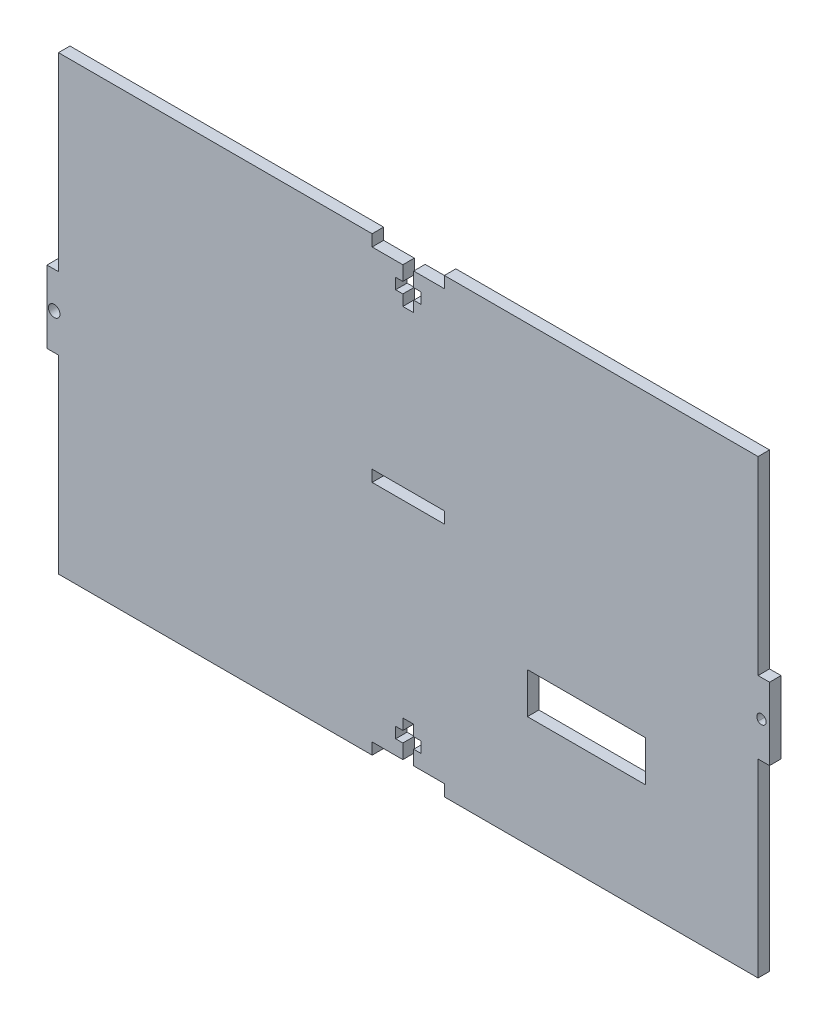
from build123d import *

# Parameters (mm, degrees)
SKETCH1_W               = 200
SKETCH1_H               = 125
BOSS_EXTRUDE1_DEPTH     = 3.18
SKETCH2_R               = 1.5
SKETCH2_W               = 3.18
SKETCH2_H               = 52.625
CUT_EXTRUDE1_DEPTH      = 4.18
SKETCH6_W               = 20
SKETCH6_H               = 3.18
CUT_EXTRUDE4_DEPTH      = 3.18
SKETCH7_W               = 32.709050062
SKETCH7_H               = 11.279604012
CUT_EXTRUDE5_DEPTH      = 3.18
SKETCH8_W               = 3.18
SKETCH8_H               = 19.75
CUT_EXTRUDE6_DEPTH      = 4.18
SKETCH9_W               = 3.18
SKETCH9_H               = 19.75
CUT_EXTRUDE7_DEPTH      = 4.18
SKETCH11_W              = 3.18
SKETCH11_H              = 20
BOSS_EXTRUDE3_DEPTH     = 3.18
CUT_EXTRUDE9_DEPTH      = 1
CUT_EXTRUDE9_DEPTH_BACK = 4.18
SKETCH13_W              = 3.18
SKETCH13_H              = 20
BOSS_EXTRUDE4_DEPTH     = 3.18
SKETCH14_R              = 1.59
CUT_EXTRUDE12_DEPTH     = 10


with BuildPart() as part:
    # Sketch1 → Boss-Extrude1 (new body)
    with BuildSketch(Plane.XY):
        Rectangle(SKETCH1_W, SKETCH1_H)
    extrude(amount=BOSS_EXTRUDE1_DEPTH)

    # Sketch2 → Cut-Extrude1 (cut, through all)
    with BuildSketch(Plane.XY.offset(3.18)):
        with Locations((-98, 0)):
            Circle(SKETCH2_R)
        with Locations((98, 0)):
            Circle(SKETCH2_R)
        Polygon((-10, 62.5), (10, 62.5), (10, 59.32), (1.5, 59.32), (1.5, 55.32), (3.5, 55.32), (3.5, 52.32), (1.5, 52.32), (1.5, 49.32), (-1.5, 49.32), (-1.5, 52.32), (-3.5, 52.32), (-3.5, 55.32), (-1.5, 55.32), (-1.5, 59.32), (-10, 59.32), align=None)
        Polygon((-10, -62.5), (-10, -59.32), (-1.5, -59.32), (-1.5, -55.32), (-3.5, -55.32), (-3.5, -52.32), (-1.5, -52.32), (-1.5, -49.32), (1.5, -49.32), (1.5, -52.32), (3.5, -52.32), (3.5, -55.32), (1.5, -55.32), (1.5, -59.32), (10, -59.32), (10, -62.5), align=None)
        with Locations((-98.41, 36.1875)):
            Rectangle(SKETCH2_W, SKETCH2_H)
        with Locations((-98.41, -36.1875)):
            Rectangle(SKETCH2_W, SKETCH2_H)
        with Locations((98.41, -36.1875)):
            Rectangle(SKETCH2_W, SKETCH2_H)
        with Locations((98.41, 36.1875)):
            Rectangle(SKETCH2_W, SKETCH2_H)
    extrude(amount=-CUT_EXTRUDE1_DEPTH, mode=Mode.SUBTRACT)

    # Sketch6 → Cut-Extrude4 (cut)
    with BuildSketch(Plane(origin=(0, 0, 0), x_dir=(-1, 0, 0), z_dir=(0, 0, -1))):
        with Locations((0, 4.478818731)):
            Rectangle(SKETCH6_W, SKETCH6_H)
    extrude(amount=-CUT_EXTRUDE4_DEPTH, mode=Mode.SUBTRACT)

    # Sketch7 → Cut-Extrude5 (cut)
    with BuildSketch(Plane(origin=(0, 0, 0), x_dir=(-1, 0, 0), z_dir=(0, 0, -1))):
        with Locations((-49.335490264, -26.125573068)):
            Rectangle(SKETCH7_W, SKETCH7_H)
    extrude(amount=-CUT_EXTRUDE5_DEPTH, mode=Mode.SUBTRACT)

    # Sketch8 → Cut-Extrude6 (cut, through all)
    with BuildSketch(Plane(origin=(0, 0, 0), x_dir=(-1, 0, 0), z_dir=(0, 0, -1))):
        with Locations((98.41, 0)):
            Rectangle(SKETCH8_W, SKETCH8_H)
    extrude(amount=-CUT_EXTRUDE6_DEPTH, mode=Mode.SUBTRACT)

    # Sketch9 → Cut-Extrude7 (cut, through all)
    with BuildSketch(Plane.XY.offset(3.18)):
        with Locations((98.41, 0)):
            Rectangle(SKETCH9_W, SKETCH9_H)
    extrude(amount=-CUT_EXTRUDE7_DEPTH, mode=Mode.SUBTRACT)

    # Sketch11 → Boss-Extrude3 (add, through all)
    with BuildSketch(Plane(origin=(0, 0, 0), x_dir=(-1, 0, 0), z_dir=(0, 0, -1))):
        with Locations((-98.41, 0)):
            Rectangle(SKETCH11_W, SKETCH11_H)
    extrude(amount=-BOSS_EXTRUDE3_DEPTH)

    # Sketch12 → Cut-Extrude9 (cut, two sides)
    with BuildSketch(Plane(origin=(0, 0, 0), x_dir=(-1, 0, 0), z_dir=(0, 0, -1))) as cut_extrude9_sk:
        with BuildLine():
            Line((-96.82, -0.926066952), (-96.82, 0.926066952))
            ThreePointArc((-96.82, 0.926066952), (-99.055723396, 0), (-96.82, -0.926066952))
        make_face()
    extrude(amount=CUT_EXTRUDE9_DEPTH, mode=Mode.SUBTRACT)
    extrude(cut_extrude9_sk.sketch, amount=-CUT_EXTRUDE9_DEPTH_BACK, mode=Mode.SUBTRACT)

    # Sketch13 → Boss-Extrude4 (add, through all)
    with BuildSketch(Plane(origin=(0, 0, 0), x_dir=(-1, 0, 0), z_dir=(0, 0, -1))):
        with Locations((98.41, 0)):
            Rectangle(SKETCH13_W, SKETCH13_H)
    extrude(amount=-BOSS_EXTRUDE4_DEPTH)

    # Sketch14 → Cut-Extrude12 (cut)
    with BuildSketch(Plane(origin=(0, 0, 0), x_dir=(-1, 0, 0), z_dir=(0, 0, -1))):
        with Locations((98, 0)):
            Circle(SKETCH14_R)
    extrude(amount=-CUT_EXTRUDE12_DEPTH, mode=Mode.SUBTRACT)


solid = part.part
